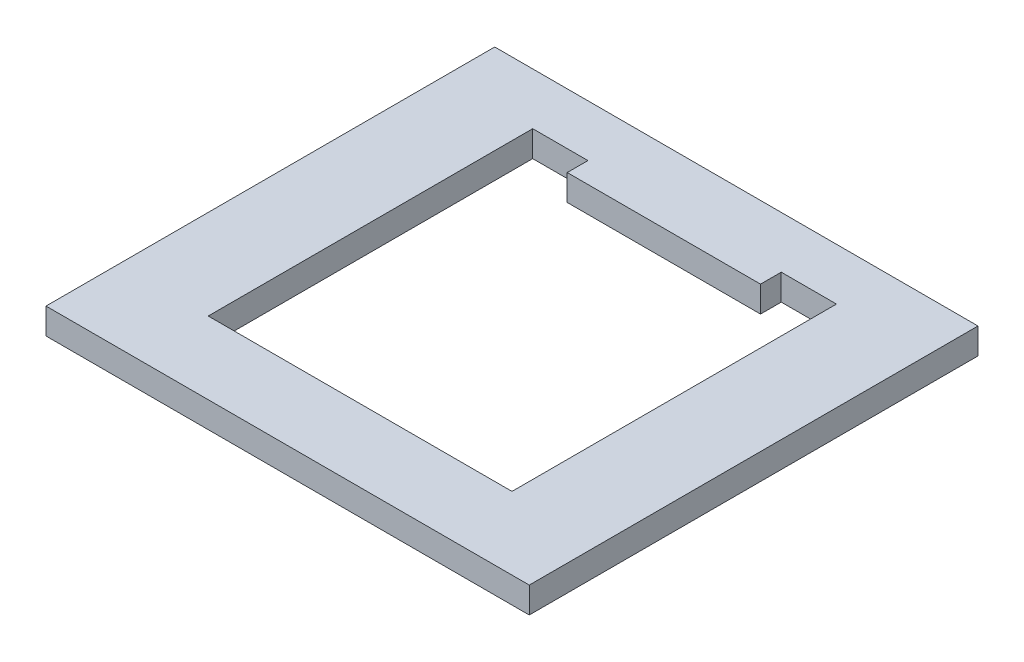
from build123d import *

# Parameters (mm, degrees)
SCHIZZO1_W                   = 70
SCHIZZO1_H                   = 65
ESTRUSIONE_ESTRUSIONE1_DEPTH = 3.76


with BuildPart() as part:
    # Schizzo1 → Estrusione-Estrusione1 (new body)
    with BuildSketch(Plane(origin=(0, 0, 0), x_dir=(1, 0, 0), z_dir=(0, 1, 0))):
        Rectangle(SCHIZZO1_W, SCHIZZO1_H)
        Polygon((-22, -22), (-22, 22), (-22, 25), (-14, 25), (-14, 22), (14, 22), (14, 25), (22, 25), (22, 22), (22, -22), align=None, mode=Mode.SUBTRACT)
    extrude(amount=ESTRUSIONE_ESTRUSIONE1_DEPTH)


solid = part.part
